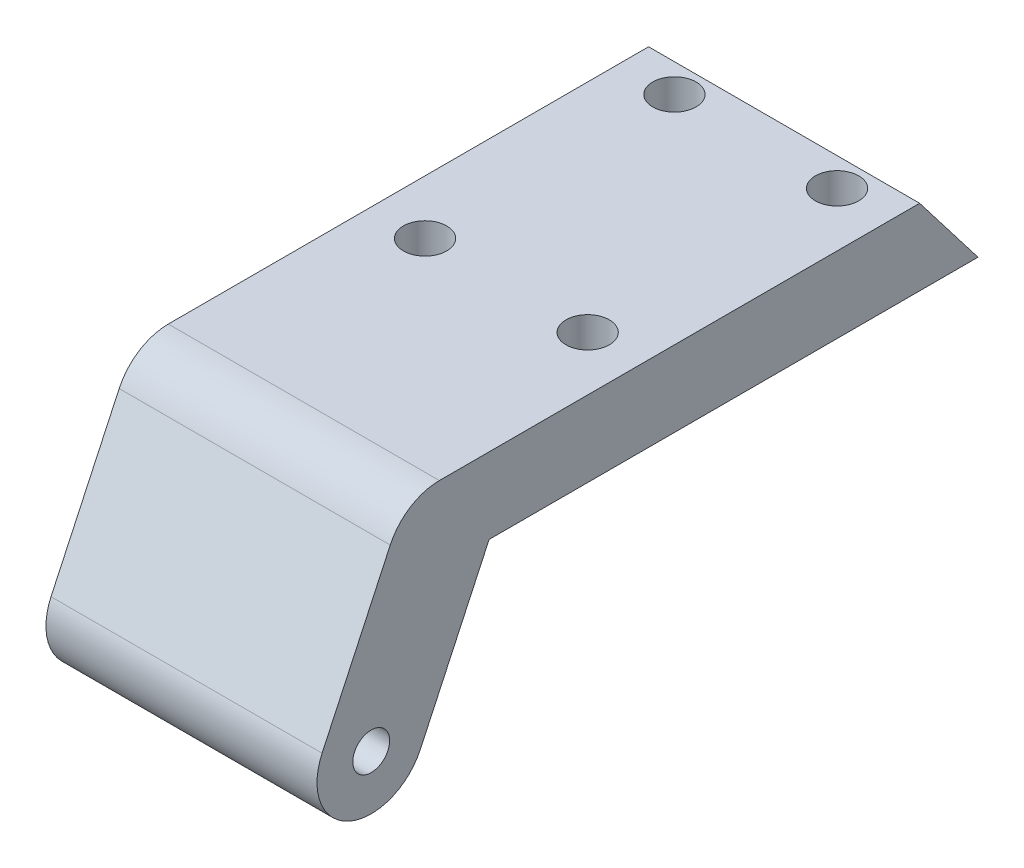
from build123d import *

# Parameters (mm, degrees)
SKETCH_1_W          = 25
SKETCH_1_H          = 43.91
EXTRUDE_1_DEPTH     = 7
CUT_EXTRUDE_1_DEPTH = 65
SKETCH_3_R          = 2
CUT_EXTRUDE_2_DEPTH = 65
SKETCH_4_W          = 25
SKETCH_4_H          = 7
EXTRUDE_2_DEPTH     = 10
SKETCH_5_R          = 1.7
EXTRUDE_3_DEPTH     = 25
FILLET_1_R          = 5


with BuildPart() as part:
    # Эскиз1 → Бобышка-Вытянуть1 (new body)
    with BuildSketch(Plane(origin=(0, 0, 0), x_dir=(1, 0, 0), z_dir=(0, 1, 0))):
        with Locations((1252.085571953, -1610.16757215)):
            Rectangle(SKETCH_1_W, SKETCH_1_H)
    extrude(amount=EXTRUDE_1_DEPTH)

    # Эскиз2 → Вырез-Вытянуть1 (cut)
    with BuildSketch(Plane(origin=(1264.585571953, 0, 0), x_dir=(0, 0, -1), z_dir=(1, 0, 0))):
        Polygon((-1594.231269333, 0), (-1599.613127302, 7), (-1588.127511269, 9.94842477), (-1585.312996238, -1.015544634), align=None)
    extrude(amount=-CUT_EXTRUDE_1_DEPTH, mode=Mode.SUBTRACT)

    # Эскиз3 → Вырез-Вытянуть2 (cut)
    with BuildSketch(Plane(origin=(0, 7, 0), x_dir=(1, 0, 0), z_dir=(0, 1, 0))):
        with Locations((1259.585571953, -1602.231269333)):
            Circle(SKETCH_3_R)
        with Locations((1259.585571953, -1625.231269333)):
            Circle(SKETCH_3_R)
        with Locations((1244.585571953, -1602.231269333)):
            Circle(SKETCH_3_R)
        with Locations((1244.585571953, -1625.231269333)):
            Circle(SKETCH_3_R)
    extrude(amount=-CUT_EXTRUDE_2_DEPTH, mode=Mode.SUBTRACT)

    # Эскиз4 → Бобышка-Вытянуть2 (add)
    with BuildSketch(Plane.XY.offset(1632.12257215)):
        with Locations((1252.085571953, 3.5)):
            Rectangle(SKETCH_4_W, SKETCH_4_H)
    extrude(amount=EXTRUDE_2_DEPTH)

    # Эскиз5 → Бобышка-Вытянуть3 (add)
    with BuildSketch(Plane(origin=(1264.585571953, 0, 0), x_dir=(0, 0, -1), z_dir=(1, 0, 0))):
        with BuildLine():
            Line((-1645.661846077, -13.594616806), (-1639.32257215, 0))
            Line((-1639.32257215, 0), (-1642.12257215, 7))
            Line((-1642.12257215, 7), (-1647.092197733, 7))
            Line((-1647.092197733, 7), (-1654.724923947, -9.368434188))
            ThreePointArc((-1654.724923947, -9.368434188), (-1652.30647632, -16.013064432), (-1645.661846077, -13.594616806))
        make_face()
        with Locations((-1650.193385012, -11.481525497)):
            Circle(SKETCH_5_R, mode=Mode.SUBTRACT)
    extrude(amount=-EXTRUDE_3_DEPTH)

    # Скругление1
    fillet_1_edges = [part.edges().sort_by_distance(p)[0] for p in [
        (1252.085571953, 7, 1647.092197733),
    ]]
    fillet(fillet_1_edges, radius=FILLET_1_R)


solid = part.part
